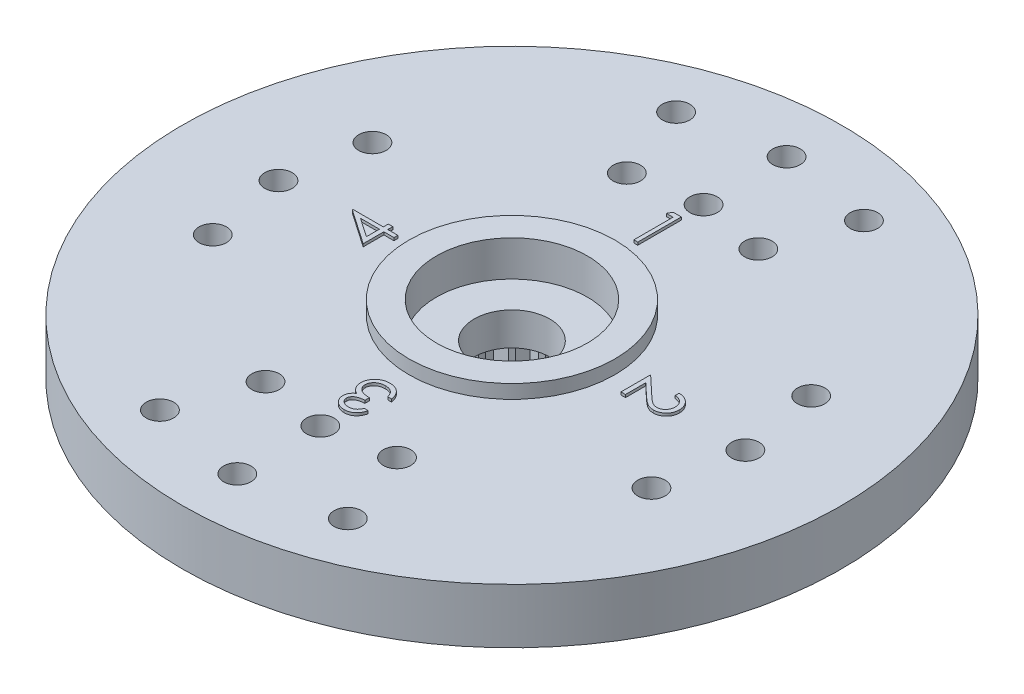
from build123d import *

# Parameters (mm, degrees)
SKETCH1_R           = 12
SKETCH1_R_2         = 1.375
SKETCH1_R_3         = 0.5
BOSS_EXTRUDE1_DEPTH = 2
SKETCH2_R           = 3.75
SKETCH2_R_2         = 2.75
BOSS_EXTRUDE2_DEPTH = 0.5
SKETCH3_R           = 2.75
SKETCH3_R_2         = 1.375
CUT_EXTRUDE1_DEPTH  = 0.8
SKETCH4_R           = 4.5
SKETCH4_R_2         = 2.5
BOSS_EXTRUDE3_DEPTH = 2.5
CUT_EXTRUDE3_DEPTH  = 2.5
BOSS_EXTRUDE4_DEPTH = 0.1


with BuildPart() as part:
    # Sketch1 → Boss-Extrude1 (new body)
    with BuildSketch(Plane(origin=(0, 0, 0), x_dir=(1, 0, 0), z_dir=(0, 1, 0))):
        Circle(SKETCH1_R)
        Circle(SKETCH1_R_2, mode=Mode.SUBTRACT)
        with Locations((0, 10)):
            Circle(SKETCH1_R_3, mode=Mode.SUBTRACT)
        with Locations((-3.420201433, 9.396926208)):
            Circle(SKETCH1_R_3, mode=Mode.SUBTRACT)
        with Locations((3.420201433, 9.396926208)):
            Circle(SKETCH1_R_3, mode=Mode.SUBTRACT)
        with Locations((0, 6.977694875)):
            Circle(SKETCH1_R_3, mode=Mode.SUBTRACT)
        with Locations((-2.394141003, 6.577848346)):
            Circle(SKETCH1_R_3, mode=Mode.SUBTRACT)
        with Locations((2.394141003, 6.577848346)):
            Circle(SKETCH1_R_3, mode=Mode.SUBTRACT)
        with Locations((8.5, 0)):
            Circle(SKETCH1_R_3, mode=Mode.SUBTRACT)
        with Locations((7.987387277, 2.907171218)):
            Circle(SKETCH1_R_3, mode=Mode.SUBTRACT)
        with Locations((7.987387277, -2.907171218)):
            Circle(SKETCH1_R_3, mode=Mode.SUBTRACT)
        with Locations((-2.394141003, -6.577848346)):
            Circle(SKETCH1_R_3, mode=Mode.SUBTRACT)
        with Locations((0, -6.977694875)):
            Circle(SKETCH1_R_3, mode=Mode.SUBTRACT)
        with Locations((2.394141003, -6.577848346)):
            Circle(SKETCH1_R_3, mode=Mode.SUBTRACT)
        with Locations((3.420201433, -9.396926208)):
            Circle(SKETCH1_R_3, mode=Mode.SUBTRACT)
        with Locations((0, -10)):
            Circle(SKETCH1_R_3, mode=Mode.SUBTRACT)
        with Locations((-3.420201433, -9.396926208)):
            Circle(SKETCH1_R_3, mode=Mode.SUBTRACT)
        with Locations((-7.987387277, -2.907171218)):
            Circle(SKETCH1_R_3, mode=Mode.SUBTRACT)
        with Locations((-8.5, 0)):
            Circle(SKETCH1_R_3, mode=Mode.SUBTRACT)
        with Locations((-7.987387277, 2.907171218)):
            Circle(SKETCH1_R_3, mode=Mode.SUBTRACT)
    extrude(amount=BOSS_EXTRUDE1_DEPTH)

    # Sketch2 → Boss-Extrude2 (add)
    with BuildSketch(Plane(origin=(0, 2, 0), x_dir=(1, 0, 0), z_dir=(0, 1, 0))):
        Circle(SKETCH2_R)
        Circle(SKETCH2_R_2, mode=Mode.SUBTRACT)
    extrude(amount=BOSS_EXTRUDE2_DEPTH)

    # Sketch3 → Cut-Extrude1 (cut)
    with BuildSketch(Plane(origin=(0, 2, 0), x_dir=(1, 0, 0), z_dir=(0, 1, 0))):
        Circle(SKETCH3_R)
        Circle(SKETCH3_R_2, mode=Mode.SUBTRACT)
    extrude(amount=-CUT_EXTRUDE1_DEPTH, mode=Mode.SUBTRACT)

    # Sketch4 → Boss-Extrude3 (add)
    with BuildSketch(Plane.XZ):
        Circle(SKETCH4_R)
        Circle(SKETCH4_R_2, mode=Mode.SUBTRACT)
    extrude(amount=BOSS_EXTRUDE3_DEPTH)

    # Sketch5 → Cut-Extrude3 (cut)
    with BuildSketch(Plane.XZ.offset(2.5)):
        with BuildLine():
            Line((0.299038106, 2.482050808), (0, 3))
            Line((0, 3), (-0.299038106, 2.482050808))
            ThreePointArc((-0.299038106, 2.482050808), (0, 2.5), (0.299038106, 2.482050808))
        make_face()
        with BuildLine():
            ThreePointArc((-1.051398019, 2.268162738), (-0.772542486, 2.377641291), (-0.482593741, 2.452978451))
            Line((-0.482593741, 2.452978451), (-0.927050983, 2.853169549))
            Line((-0.927050983, 2.853169549), (-1.051398019, 2.268162738))
        make_face()
        with BuildLine():
            Line((0.927050983, 2.853169549), (0.482593741, 2.452978451))
            ThreePointArc((0.482593741, 2.452978451), (0.772542486, 2.377641291), (1.051398019, 2.268162738))
            Line((1.051398019, 2.268162738), (0.927050983, 2.853169549))
        make_face()
        with BuildLine():
            ThreePointArc((-1.70083977, 1.832251096), (-1.469463131, 2.022542486), (-1.216985951, 2.183791473))
            Line((-1.216985951, 2.183791473), (-1.763355757, 2.427050983))
            Line((-1.763355757, 2.427050983), (-1.70083977, 1.832251096))
        make_face()
        with BuildLine():
            Line((1.763355757, 2.427050983), (1.216985951, 2.183791473))
            ThreePointArc((1.216985951, 2.183791473), (1.469463131, 2.022542486), (1.70083977, 1.832251096))
            Line((1.70083977, 1.832251096), (1.763355757, 2.427050983))
        make_face()
        with BuildLine():
            ThreePointArc((-2.183791473, 1.216985951), (-2.022542486, 1.469463131), (-1.832251096, 1.70083977))
            Line((-1.832251096, 1.70083977), (-2.427050983, 1.763355757))
            Line((-2.427050983, 1.763355757), (-2.183791473, 1.216985951))
        make_face()
        with BuildLine():
            Line((2.427050983, 1.763355757), (1.832251096, 1.70083977))
            ThreePointArc((1.832251096, 1.70083977), (2.022542486, 1.469463131), (2.183791473, 1.216985951))
            Line((2.183791473, 1.216985951), (2.427050983, 1.763355757))
        make_face()
        with BuildLine():
            ThreePointArc((-2.452978451, 0.482593741), (-2.377641291, 0.772542486), (-2.268162738, 1.051398019))
            Line((-2.268162738, 1.051398019), (-2.853169549, 0.927050983))
            Line((-2.853169549, 0.927050983), (-2.452978451, 0.482593741))
        make_face()
        with BuildLine():
            Line((2.853169549, 0.927050983), (2.268162738, 1.051398019))
            ThreePointArc((2.268162738, 1.051398019), (2.377641291, 0.772542486), (2.452978451, 0.482593741))
            Line((2.452978451, 0.482593741), (2.853169549, 0.927050983))
        make_face()
        with BuildLine():
            ThreePointArc((-2.482050808, -0.299038106), (-2.5, 0), (-2.482050808, 0.299038106))
            Line((-2.482050808, 0.299038106), (-3, 0))
            Line((-3, 0), (-2.482050808, -0.299038106))
        make_face()
        with BuildLine():
            Line((3, 0), (2.482050808, 0.299038106))
            ThreePointArc((2.482050808, 0.299038106), (2.5, 0), (2.482050808, -0.299038106))
            Line((2.482050808, -0.299038106), (3, 0))
        make_face()
        with BuildLine():
            ThreePointArc((-2.268162738, -1.051398019), (-2.377641291, -0.772542486), (-2.452978451, -0.482593741))
            Line((-2.452978451, -0.482593741), (-2.853169549, -0.927050983))
            Line((-2.853169549, -0.927050983), (-2.268162738, -1.051398019))
        make_face()
        with BuildLine():
            Line((2.853169549, -0.927050983), (2.452978451, -0.482593741))
            ThreePointArc((2.452978451, -0.482593741), (2.377641291, -0.772542486), (2.268162738, -1.051398019))
            Line((2.268162738, -1.051398019), (2.853169549, -0.927050983))
        make_face()
        with BuildLine():
            ThreePointArc((-1.832251096, -1.70083977), (-2.022542486, -1.469463131), (-2.183791473, -1.216985951))
            Line((-2.183791473, -1.216985951), (-2.427050983, -1.763355757))
            Line((-2.427050983, -1.763355757), (-1.832251096, -1.70083977))
        make_face()
        with BuildLine():
            Line((2.427050983, -1.763355757), (2.183791473, -1.216985951))
            ThreePointArc((2.183791473, -1.216985951), (2.022542486, -1.469463131), (1.832251096, -1.70083977))
            Line((1.832251096, -1.70083977), (2.427050983, -1.763355757))
        make_face()
        with BuildLine():
            ThreePointArc((-1.216985951, -2.183791473), (-1.469463131, -2.022542486), (-1.70083977, -1.832251096))
            Line((-1.70083977, -1.832251096), (-1.763355757, -2.427050983))
            Line((-1.763355757, -2.427050983), (-1.216985951, -2.183791473))
        make_face()
        with BuildLine():
            Line((1.763355757, -2.427050983), (1.70083977, -1.832251096))
            ThreePointArc((1.70083977, -1.832251096), (1.469463131, -2.022542486), (1.216985951, -2.183791473))
            Line((1.216985951, -2.183791473), (1.763355757, -2.427050983))
        make_face()
        with BuildLine():
            ThreePointArc((-0.482593741, -2.452978451), (-0.772542486, -2.377641291), (-1.051398019, -2.268162738))
            Line((-1.051398019, -2.268162738), (-0.927050983, -2.853169549))
            Line((-0.927050983, -2.853169549), (-0.482593741, -2.452978451))
        make_face()
        with BuildLine():
            Line((0.927050983, -2.853169549), (1.051398019, -2.268162738))
            ThreePointArc((1.051398019, -2.268162738), (0.772542486, -2.377641291), (0.482593741, -2.452978451))
            Line((0.482593741, -2.452978451), (0.927050983, -2.853169549))
        make_face()
        with BuildLine():
            ThreePointArc((0.299038106, -2.482050808), (0, -2.5), (-0.299038106, -2.482050808))
            Line((-0.299038106, -2.482050808), (0, -3))
            Line((0, -3), (0.299038106, -2.482050808))
        make_face()
    extrude(amount=-CUT_EXTRUDE3_DEPTH, mode=Mode.SUBTRACT)

    # Sketch6 → Boss-Extrude4 (add)
    with BuildSketch(Plane(origin=(0, 2, 0), x_dir=(1, 0, 0), z_dir=(0, 1, 0))):
        Polygon((-0.212111879, 6.0875), (0.081410256, 6.0875), (0.081410256, 4.5), (-0.061057692, 4.5), (-0.061057692, 5.924679487), (-0.305288462, 5.924679487), align=None)
        with BuildLine():
            Line((5.599038462, 0.34599359), (5.599038462, 0.488461538))
            add(Edge.make_bspline(
                [(5.599038462, 0.488461538), (5.617939279, 0.487533166), (5.655059981, 0.485709868), (5.709180577, 0.477167658), (5.760917347, 0.46495614), (5.809826741, 0.447649569), (5.856493025, 0.426277468), (5.900296523, 0.40011183), (5.941671981, 0.369710466), (5.979836023, 0.335129148), (6.014722729, 0.29760523), (6.045167992, 0.25736354), (6.070596953, 0.214817686), (6.091970581, 0.170336692), (6.107994605, 0.123406123), (6.119889389, 0.074474582), (6.127044708, 0.023320904), (6.12781392, -0.011531495), (6.128205128, -0.029256811)],
                knots=[0, 0, 0, 0, 5.6734e-05, 0.000111424, 0.000164104, 0.000216001, 0.000266797, 0.000317845, 0.000368792, 0.000420582, 0.000472116, 0.000522298, 0.000571655, 0.000620588, 0.000670069, 0.000720126, 0.000771487, 0.000824641, 0.000824641, 0.000824641, 0.000824641], degree=3))
            add(Edge.make_bspline(
                [(6.128205128, -0.029256811), (6.127797614, -0.046664009), (6.126996863, -0.080868531), (6.120120254, -0.130789516), (6.109349932, -0.178313503), (6.094239011, -0.223347597), (6.073926074, -0.265532491), (6.049525047, -0.305185086), (6.02130391, -0.342777454), (5.988078073, -0.376616959), (5.952607706, -0.407690267), (5.914739978, -0.434497361), (5.875628838, -0.457454046), (5.834976046, -0.476589172), (5.79239883, -0.490675349), (5.748517063, -0.501369751), (5.702876523, -0.507414685), (5.671985336, -0.50834243), (5.656280048, -0.508814103)],
                knots=[0, 0, 0, 0, 5.2201e-05, 0.000102573, 0.000150864, 0.00019823, 0.000244744, 0.000290994, 0.000337742, 0.000385422, 0.000432989, 0.000479051, 0.000524375, 0.000568907, 0.000613558, 0.00065868, 0.00070424, 0.000751358, 0.000751358, 0.000751358, 0.000751358], degree=3))
            add(Edge.make_bspline(
                [(5.656280048, -0.508814103), (5.634169423, -0.508046087), (5.590336183, -0.506523533), (5.525922299, -0.493499512), (5.463513856, -0.473158416), (5.413286579, -0.448666758), (5.372812816, -0.423959614), (5.339489511, -0.401694923), (5.30360953, -0.375630526), (5.265293024, -0.345387065), (5.224239863, -0.311590155), (5.180474849, -0.273933674), (5.134450153, -0.232149094), (5.103015113, -0.202821846), (5.086726262, -0.1876252)],
                knots=[0, 0, 0, 0, 6.6275e-05, 0.000131387, 0.000196351, 0.000262772, 0.00029844, 0.000338571, 0.000382971, 0.000431446, 0.00048499, 0.000542489, 0.000604632, 0.000671463, 0.000671463, 0.000671463, 0.000671463], degree=3))
            Line((5.086726262, -0.1876252), (4.662820513, 0.209567808))
            Line((4.662820513, 0.209567808), (4.662820513, -0.529166667))
            Line((4.662820513, -0.529166667), (4.5, -0.529166667))
            Line((4.5, -0.529166667), (4.5, 0.549519231))
            Line((4.5, 0.549519231), (5.15700621, -0.066145833))
            add(Edge.make_bspline(
                [(5.15700621, -0.066145833), (5.172652803, -0.081136472), (5.202706705, -0.10993042), (5.246597776, -0.15063927), (5.287268318, -0.187261175), (5.324898551, -0.219820431), (5.359275147, -0.248343825), (5.390667508, -0.272740096), (5.418806234, -0.293117072), (5.451862432, -0.31471242), (5.492269991, -0.335305017), (5.541401752, -0.353403803), (5.592090897, -0.364360562), (5.626334746, -0.36568164), (5.643559696, -0.366346154)],
                knots=[0, 0, 0, 0, 6.5005e-05, 0.000124862, 0.000179583, 0.000229184, 0.000274136, 0.000313574, 0.000348435, 0.000378338, 0.000431957, 0.000484068, 0.000535086, 0.000586722, 0.000586722, 0.000586722, 0.000586722], degree=3))
            add(Edge.make_bspline(
                [(5.643559696, -0.366346154), (5.654392812, -0.366060761), (5.675742806, -0.365498307), (5.707024672, -0.360440353), (5.737316681, -0.353009214), (5.766244292, -0.341555532), (5.794376458, -0.327794356), (5.820857871, -0.310213439), (5.846591221, -0.290123068), (5.87069413, -0.266819222), (5.892776139, -0.241235929), (5.912335573, -0.214204803), (5.928681993, -0.185607306), (5.94208205, -0.155562618), (5.952593749, -0.124154868), (5.959877459, -0.091323211), (5.964450586, -0.057158391), (5.965069336, -0.033829626), (5.965384615, -0.021942608)],
                knots=[0, 0, 0, 0, 3.2476e-05, 6.4004e-05, 9.4855e-05, 0.000125861, 0.000157149, 0.000188638, 0.00022102, 0.000254982, 0.000289027, 0.000322298, 0.000354918, 0.000387659, 0.000420845, 0.000454096, 0.000488413, 0.000524066, 0.000524066, 0.000524066, 0.000524066], degree=3))
            add(Edge.make_bspline(
                [(5.965384615, -0.021942608), (5.965060395, -0.009527925), (5.964423681, 0.014852462), (5.959967009, 0.050647099), (5.952285925, 0.084797422), (5.941755322, 0.117372561), (5.928497209, 0.148403903), (5.911665037, 0.177610862), (5.891915995, 0.205260088), (5.869403165, 0.231300798), (5.844219896, 0.255228126), (5.816492727, 0.276692883), (5.786041295, 0.295000051), (5.753553406, 0.311228532), (5.718165248, 0.323645722), (5.680734357, 0.334259816), (5.64072893, 0.341970171), (5.613166096, 0.344630175), (5.599038462, 0.34599359)],
                knots=[0, 0, 0, 0, 3.7241e-05, 7.3135e-05, 0.000108008, 0.0001421, 0.000175714, 0.000209044, 0.000243018, 0.000277511, 0.000312152, 0.000347072, 0.000382469, 0.000418593, 0.000455815, 0.00049478, 0.000535257, 0.00057782, 0.00057782, 0.00057782, 0.00057782], degree=3))
        make_face()
        with BuildLine():
            Line((0.34599359, -5.721153846), (0.488461538, -5.721153846))
            add(Edge.make_bspline(
                [(0.488461538, -5.721153846), (0.484601849, -5.737134294), (0.477056473, -5.768374763), (0.461318645, -5.813009485), (0.444173983, -5.855247654), (0.423586782, -5.894298373), (0.401131025, -5.930946447), (0.37540322, -5.964360657), (0.347590345, -5.995390823), (0.316826886, -6.022928613), (0.284564958, -6.04786494), (0.250349969, -6.069126127), (0.2148703, -6.08741601), (0.177880129, -6.102483759), (0.139269329, -6.113834621), (0.099386965, -6.122070029), (0.05812852, -6.127418142), (0.030121577, -6.127940095), (0.015900441, -6.128205128)],
                knots=[0, 0, 0, 0, 4.9287e-05, 9.6353e-05, 0.000141828, 0.000185921, 0.00022863, 0.000270609, 0.000312258, 0.000353458, 0.000394292, 0.00043444, 0.000474121, 0.000513923, 0.000554069, 0.000594671, 0.000636008, 0.000678651, 0.000678651, 0.000678651, 0.000678651], degree=3))
            add(Edge.make_bspline(
                [(0.015900441, -6.128205128), (-0.004819946, -6.127579549), (-0.045808747, -6.126342036), (-0.106026272, -6.115041559), (-0.164095579, -6.097159445), (-0.21938106, -6.072451719), (-0.270733706, -6.041977474), (-0.316424762, -6.005707754), (-0.355834908, -5.964342356), (-0.388897715, -5.918652943), (-0.414785304, -5.86982348), (-0.43387448, -5.819567694), (-0.445495743, -5.7680048), (-0.447001853, -5.733189891), (-0.44775641, -5.715747696)],
                knots=[0, 0, 0, 0, 6.211e-05, 0.000122866, 0.000183117, 0.000244047, 0.000304093, 0.000361803, 0.000418486, 0.000474973, 0.000530457, 0.000583793, 0.000635878, 0.00068817, 0.00068817, 0.00068817, 0.00068817], degree=3))
            add(Edge.make_bspline(
                [(-0.44775641, -5.715747696), (-0.447228639, -5.698962472), (-0.446195871, -5.666116392), (-0.437426655, -5.618164141), (-0.422669136, -5.572969558), (-0.402226779, -5.530342388), (-0.375764719, -5.490552907), (-0.343709603, -5.453511592), (-0.305835181, -5.419054153), (-0.277133663, -5.399314963), (-0.262357272, -5.389152644)],
                knots=[0, 0, 0, 0, 5.0327e-05, 9.8482e-05, 0.000145647, 0.000192584, 0.00023986, 0.000288564, 0.000339219, 0.000392971, 0.000392971, 0.000392971, 0.000392971], degree=3))
            add(Edge.make_bspline(
                [(-0.262357272, -5.389152644), (-0.279266057, -5.38102782), (-0.312821544, -5.364904106), (-0.358097689, -5.332780608), (-0.399825574, -5.296601576), (-0.422822908, -5.268052723), (-0.43440004, -5.253680889)],
                knots=[0, 0, 0, 0, 5.6181e-05, 0.00011149, 0.000165999, 0.000221257, 0.000221257, 0.000221257, 0.000221257], degree=3))
            add(Edge.make_bspline(
                [(-0.43440004, -5.253680889), (-0.442041901, -5.243223667), (-0.457200483, -5.222480465), (-0.475858316, -5.189110161), (-0.492978135, -5.155480456), (-0.505577827, -5.120269074), (-0.516450862, -5.084607067), (-0.523604956, -5.047730768), (-0.528197599, -5.009990535), (-0.5288425, -4.984446887), (-0.529166667, -4.971607071)],
                knots=[0, 0, 0, 0, 3.8818e-05, 7.7e-05, 0.000114547, 0.000151879, 0.000189009, 0.000226305, 0.000264409, 0.000302921, 0.000302921, 0.000302921, 0.000302921], degree=3))
            add(Edge.make_bspline(
                [(-0.529166667, -4.971607071), (-0.528350817, -4.94937866), (-0.526722958, -4.905026444), (-0.512235463, -4.839481871), (-0.489636803, -4.775530087), (-0.458141824, -4.71407805), (-0.418998333, -4.656756936), (-0.372686258, -4.605322495), (-0.319156288, -4.561514187), (-0.259966982, -4.524586511), (-0.195593193, -4.495321744), (-0.127013944, -4.474234108), (-0.05463527, -4.461584484), (-0.005138768, -4.460066765), (0.020034555, -4.459294872)],
                knots=[0, 0, 0, 0, 6.6613e-05, 0.000132912, 0.000200403, 0.000269665, 0.000339437, 0.000408104, 0.00047655, 0.00054626, 0.000616846, 0.000688063, 0.000760995, 0.000836477, 0.000836477, 0.000836477, 0.000836477], degree=3))
            add(Edge.make_bspline(
                [(0.020034555, -4.459294872), (0.037005812, -4.459692103), (0.070399587, -4.460473722), (0.11951096, -4.465721886), (0.166290723, -4.475567824), (0.211193125, -4.487950453), (0.253540479, -4.505070826), (0.293941914, -4.525481482), (0.332220335, -4.549705826), (0.36814842, -4.577784596), (0.401687783, -4.60921458), (0.431983954, -4.644517919), (0.459372127, -4.683035728), (0.48367828, -4.725114484), (0.50500471, -4.770636328), (0.52289247, -4.819783675), (0.538510693, -4.872175513), (0.545786309, -4.908676289), (0.549519231, -4.927403846)],
                knots=[0, 0, 0, 0, 5.0917e-05, 0.000100188, 0.000147899, 0.000194202, 0.000239731, 0.000284673, 0.000329844, 0.00037539, 0.000421283, 0.000467504, 0.000514711, 0.000562874, 0.000613093, 0.000665313, 0.000719655, 0.000776914, 0.000776914, 0.000776914, 0.000776914], degree=3))
            Line((0.549519231, -4.927403846), (0.407051282, -4.927403846))
            add(Edge.make_bspline(
                [(0.407051282, -4.927403846), (0.403339575, -4.915180544), (0.396119982, -4.891405159), (0.383830783, -4.857187592), (0.369829816, -4.825819475), (0.354809999, -4.797070701), (0.339035489, -4.770658147), (0.321384791, -4.747280228), (0.303165214, -4.725910119), (0.289431365, -4.713870241), (0.282709836, -4.707977764)],
                knots=[0, 0, 0, 0, 3.8321e-05, 7.4538e-05, 0.00010899, 0.000141279, 0.000171821, 0.000201141, 0.000229083, 0.000255865, 0.000255865, 0.000255865, 0.000255865], degree=3))
            add(Edge.make_bspline(
                [(0.282709836, -4.707977764), (0.273820396, -4.701127882), (0.256068955, -4.68744926), (0.227160407, -4.669943613), (0.196651098, -4.654959198), (0.164286602, -4.642779237), (0.130062577, -4.63363652), (0.094117851, -4.627056022), (0.056393446, -4.622711871), (0.030647277, -4.622317113), (0.017490485, -4.622115385)],
                knots=[0, 0, 0, 0, 3.3646e-05, 6.7188e-05, 0.000101179, 0.000135496, 0.000170751, 0.000207301, 0.000245053, 0.000284507, 0.000284507, 0.000284507, 0.000284507], degree=3))
            add(Edge.make_bspline(
                [(0.017490485, -4.622115385), (0.002634231, -4.622394287), (-0.026415892, -4.622939657), (-0.068801536, -4.627969629), (-0.109137453, -4.635263244), (-0.147012014, -4.646671877), (-0.182940598, -4.660358417), (-0.216121178, -4.678276609), (-0.247529219, -4.69851231), (-0.276244612, -4.722050322), (-0.302132943, -4.747492366), (-0.324503322, -4.774484107), (-0.343878628, -4.802188626), (-0.35945314, -4.831252213), (-0.371773311, -4.861389777), (-0.380155306, -4.892714125), (-0.385984774, -4.924961484), (-0.386459435, -4.946882168), (-0.386698718, -4.957932692)],
                knots=[0, 0, 0, 0, 4.455e-05, 8.7113e-05, 0.000127902, 0.000167348, 0.000205615, 0.000243028, 0.00028025, 0.00031755, 0.000354203, 0.000388976, 0.000422584, 0.000455451, 0.000487694, 0.00052002, 0.000552591, 0.000585702, 0.000585702, 0.000585702, 0.000585702], degree=3))
            add(Edge.make_bspline(
                [(-0.386698718, -4.957932692), (-0.386003169, -4.972723335), (-0.384615531, -5.002231023), (-0.374065118, -5.0456597), (-0.356555994, -5.087519235), (-0.332520572, -5.127261442), (-0.302560837, -5.163663871), (-0.268092983, -5.196247969), (-0.228381575, -5.223379244), (-0.191624295, -5.242072337), (-0.158981256, -5.254526807), (-0.131102444, -5.263260269), (-0.099863368, -5.270241472), (-0.06563939, -5.276994458), (-0.028286064, -5.282655717), (0.012230232, -5.287397248), (0.055925805, -5.291185256), (0.086174952, -5.292877803), (0.101762821, -5.29375)],
                knots=[0, 0, 0, 0, 4.4341e-05, 8.8462e-05, 0.000133228, 0.000180022, 0.000227256, 0.000274279, 0.000321825, 0.000371033, 0.00039761, 0.000426578, 0.00045859, 0.000493578, 0.000531223, 0.000571891, 0.000615941, 0.000662776, 0.000662776, 0.000662776, 0.000662776], degree=3))
            Line((0.101762821, -5.29375), (0.101762821, -5.456570513))
            add(Edge.make_bspline(
                [(0.101762821, -5.456570513), (0.082130288, -5.456953283), (0.043688426, -5.457702772), (-0.012623157, -5.464900992), (-0.066305692, -5.47658472), (-0.116551716, -5.492896722), (-0.162112282, -5.512755295), (-0.202016873, -5.53498931), (-0.234829912, -5.560639777), (-0.261139083, -5.588494162), (-0.280652882, -5.618558339), (-0.295056815, -5.64975068), (-0.303576438, -5.682651469), (-0.304715777, -5.70510004), (-0.305288462, -5.716383714)],
                knots=[0, 0, 0, 0, 5.8874e-05, 0.000115279, 0.000169985, 0.000223486, 0.00027347, 0.00031891, 0.000360133, 0.000397935, 0.000433304, 0.000467176, 0.00050065, 0.00053448, 0.00053448, 0.00053448, 0.00053448], degree=3))
            add(Edge.make_bspline(
                [(-0.305288462, -5.716383714), (-0.305104632, -5.724675376), (-0.304738912, -5.741171245), (-0.299942506, -5.765346601), (-0.293068021, -5.788783239), (-0.283080788, -5.811207319), (-0.270164259, -5.832690124), (-0.254537181, -5.853310117), (-0.236159971, -5.8732642), (-0.215151965, -5.892112288), (-0.191706493, -5.9090759), (-0.166764563, -5.924198724), (-0.140228938, -5.936914866), (-0.112272542, -5.947455684), (-0.082744259, -5.95537096), (-0.051799429, -5.961057912), (-0.019374439, -5.964612556), (0.002746995, -5.965124413), (0.013992388, -5.965384615)],
                knots=[0, 0, 0, 0, 2.4837e-05, 4.9413e-05, 7.3659e-05, 9.8004e-05, 0.000122819, 0.000148705, 0.000175488, 0.000204089, 0.000233221, 0.000262181, 0.000291481, 0.000321369, 0.000351687, 0.00038306, 0.000415685, 0.000449418, 0.000449418, 0.000449418, 0.000449418], degree=3))
            add(Edge.make_bspline(
                [(0.013992388, -5.965384615), (0.032068563, -5.964754757), (0.067375538, -5.963524498), (0.118264696, -5.952711076), (0.16552422, -5.935578323), (0.201526445, -5.914890575), (0.228156868, -5.894539373), (0.24755157, -5.877031234), (0.266250048, -5.85718059), (0.283518559, -5.83444296), (0.300391868, -5.809600201), (0.31670886, -5.782515486), (0.331945433, -5.752802669), (0.341220184, -5.73190776), (0.34599359, -5.721153846)],
                knots=[0, 0, 0, 0, 5.4175e-05, 0.000105816, 0.000155319, 0.000204466, 0.000229653, 0.000255773, 0.000282772, 0.000311332, 0.000341321, 0.000372844, 0.000406126, 0.000441419, 0.000441419, 0.000441419, 0.000441419], degree=3))
        make_face()
        Polygon((-6.128205128, 0.317054788), (-6.128205128, 0.34599359), (-5.029166667, 0.34599359), (-5.029166667, 0.529166667), (-4.866346154, 0.529166667), (-4.866346154, 0.34599359), (-4.5, 0.34599359), (-4.5, 0.203525641), (-4.866346154, 0.203525641), (-4.866346154, -0.549519231), align=None)
        Polygon((-5.029166667, 0.203525641), (-5.718609776, 0.203525641), (-5.029166667, -0.269671474), align=None, mode=Mode.SUBTRACT)
    extrude(amount=BOSS_EXTRUDE4_DEPTH)


solid = part.part
